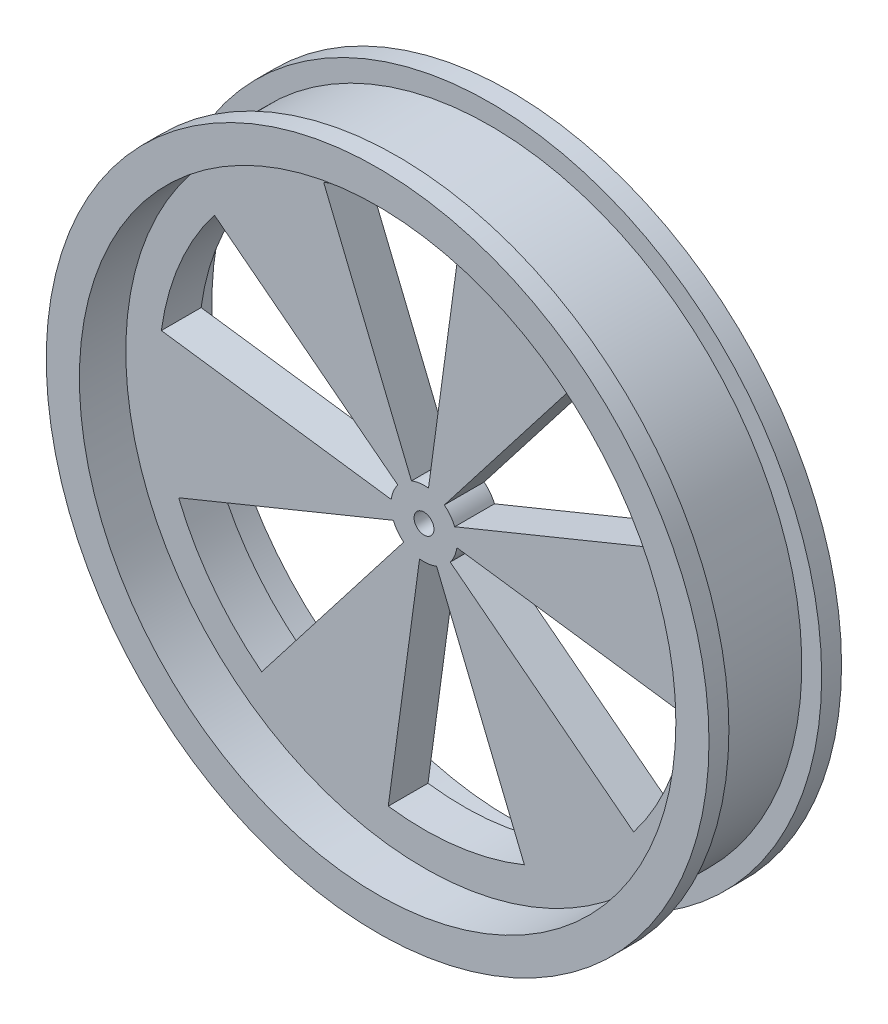
from build123d import *

# Parameters (mm, degrees)
ESQUISSE2_R             = 50
BOSS_EXTRU_1_DEPTH      = 20
ESQUISSE3_R             = 45
ENL_V_MAT_EXTRU_1_DEPTH = 7
ESQUISSE4_R             = 45
ENL_V_MAT_EXTRU_2_DEPTH = 7
ENL_V_MAT_EXTRU_3_DEPTH = 14
ESQUISSE7_W             = 14
ESQUISSE7_H             = 4.126499196
ESQUISSE8_R             = 1.5
ENL_V_MAT_EXTRU_4_DEPTH = 21


with BuildPart() as part:
    # Esquisse2 → Boss.-Extru.1 (new body)
    with BuildSketch(Plane.XY):
        Circle(ESQUISSE2_R)
    extrude(amount=BOSS_EXTRU_1_DEPTH)

    # Esquisse3 → Enlèv. mat.-Extru.1 (cut)
    with BuildSketch(Plane.XY):
        Circle(ESQUISSE3_R)
    extrude(amount=ENL_V_MAT_EXTRU_1_DEPTH, mode=Mode.SUBTRACT)

    # Esquisse4 → Enlèv. mat.-Extru.2 (cut)
    with BuildSketch(Plane.XY.offset(20)):
        Circle(ESQUISSE4_R)
    extrude(amount=-ENL_V_MAT_EXTRU_2_DEPTH, mode=Mode.SUBTRACT)

    # Esquisse6 → Enlèv. mat.-Extru.3 (cut, through all)
    with BuildSketch(Plane.XY.offset(13)):
        with BuildLine():
            ThreePointArc((3.061476111, 3.953146092), (3.980308338, 3.026077582), (4.627889131, 1.892786885))
            Line((4.627889131, 1.892786885), (37.023113047, 15.142295082))
            ThreePointArc((37.023113047, 15.142295082), (31.842466708, 24.208620654), (24.491808885, 31.625168736))
            Line((24.491808885, 31.625168736), (3.061476111, 3.953146092))
        make_face()
        with BuildLine():
            ThreePointArc((-1.892786885, 4.627889131), (-0.63050589, 4.960086927), (0.674743039, 4.954262996))
            Line((0.674743039, 4.954262996), (5.397944311, 39.634103966))
            ThreePointArc((5.397944311, 39.634103966), (-5.044047123, 39.680695415), (-15.142295082, 37.023113047))
            Line((-15.142295082, 37.023113047), (-1.892786885, 4.627889131))
        make_face()
        with BuildLine():
            ThreePointArc((-4.954262996, 0.674743039), (-4.610814229, 1.934009345), (-3.953146092, 3.061476111))
            Line((-3.953146092, 3.061476111), (-31.625168736, 24.491808885))
            ThreePointArc((-31.625168736, 24.491808885), (-36.886513831, 15.472074761), (-39.634103966, 5.397944311))
            Line((-39.634103966, 5.397944311), (-4.954262996, 0.674743039))
        make_face()
        with BuildLine():
            Line((-24.491808885, -31.625168736), (-3.061476111, -3.953146092))
            ThreePointArc((-3.061476111, -3.953146092), (-3.980308338, -3.026077582), (-4.627889131, -1.892786885))
            Line((-4.627889131, -1.892786885), (-37.023113047, -15.142295082))
            ThreePointArc((-37.023113047, -15.142295082), (-31.842466708, -24.208620654), (-24.491808885, -31.625168736))
        make_face()
        with BuildLine():
            Line((15.142295082, -37.023113047), (1.892786885, -4.627889131))
            ThreePointArc((1.892786885, -4.627889131), (0.63050589, -4.960086927), (-0.674743039, -4.954262996))
            Line((-0.674743039, -4.954262996), (-5.397944311, -39.634103966))
            ThreePointArc((-5.397944311, -39.634103966), (5.044047123, -39.680695415), (15.142295082, -37.023113047))
        make_face()
        with BuildLine():
            Line((39.634103966, -5.397944311), (4.954262996, -0.674743039))
            ThreePointArc((4.954262996, -0.674743039), (4.610814229, -1.934009345), (3.953146092, -3.061476111))
            Line((3.953146092, -3.061476111), (31.625168736, -24.491808885))
            ThreePointArc((31.625168736, -24.491808885), (36.886513831, -15.472074761), (39.634103966, -5.397944311))
        make_face()
    extrude(amount=-ENL_V_MAT_EXTRU_3_DEPTH, mode=Mode.SUBTRACT)

    # Esquisse7 → Enlèvement de matière-Révolution1 (revolve, cut)
    with BuildSketch(Plane(origin=(0, 0, 0), x_dir=(0, 0, -1), z_dir=(1, 0, 0))):
        with Locations((-10, 49.063249598)):
            Rectangle(ESQUISSE7_W, ESQUISSE7_H)
    revolve(axis=Axis((0, 0, 0), (0, 0, 1)), mode=Mode.SUBTRACT)

    # Esquisse8 → Enlèv. mat.-Extru.4 (cut, through all)
    with BuildSketch(Plane.XY):
        Circle(ESQUISSE8_R)
    extrude(amount=ENL_V_MAT_EXTRU_4_DEPTH, mode=Mode.SUBTRACT)


solid = part.part
